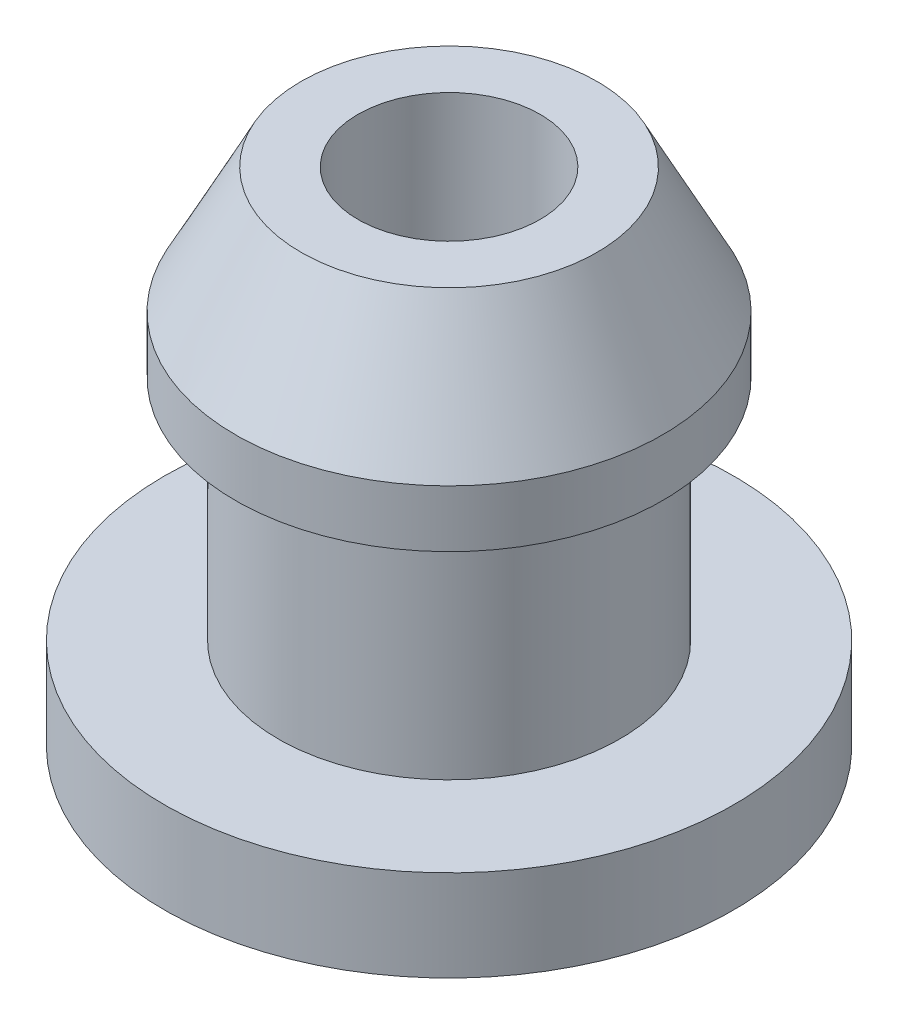
from build123d import *


with BuildPart() as part:
    # Esquisse1 → Révolution1 (revolve)
    with BuildSketch(Plane.XY):
        Polygon((0, -4.4), (5, -4.4), (5, -2.8), (3, -2.8), (3, 1.2), (3.75, 1.2), (3.75, 2.2), (2.6, 4.4), (1.6, 4.4), (1.6, -1.6), (0, -1.6), align=None)
    revolve(axis=Axis((0, 5.28, 0), (0, -1, 0)))


solid = part.part
